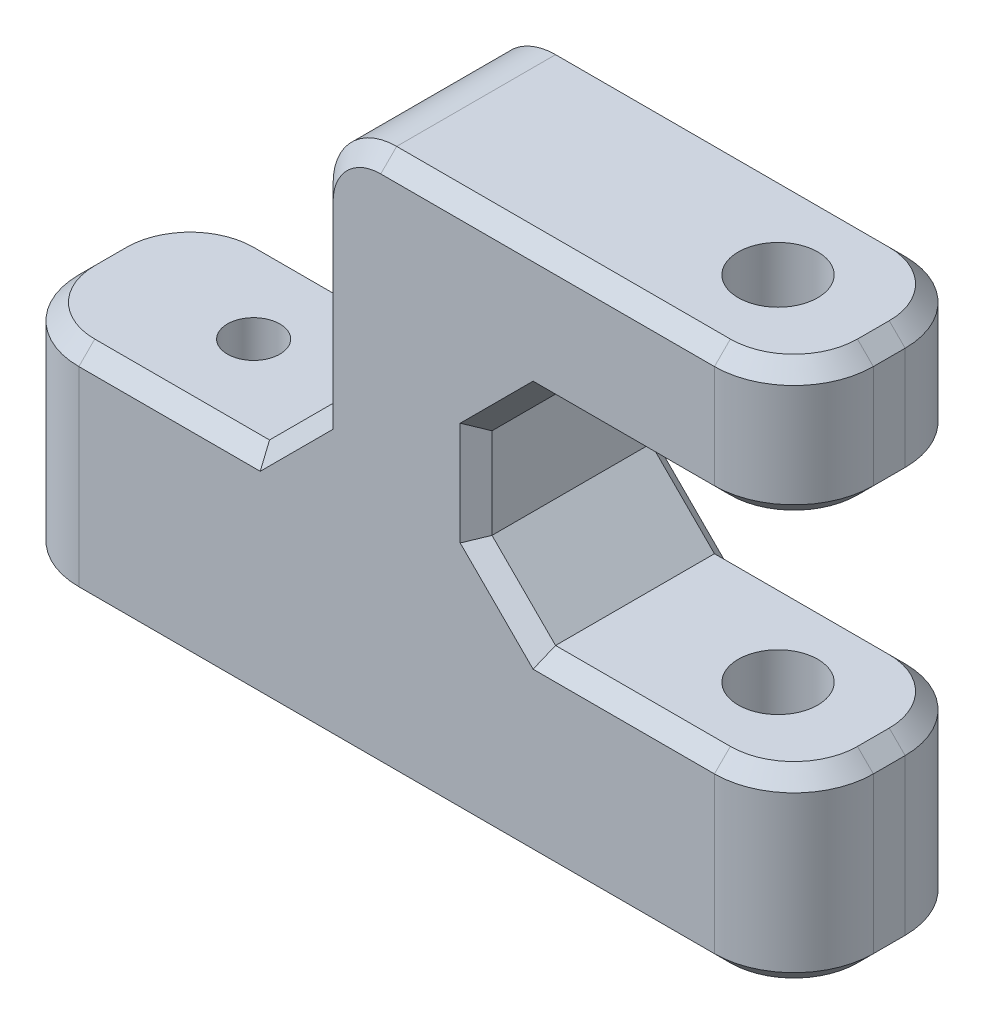
from build123d import *

# Parameters (mm, degrees)
BOSS_EXTRUDE1_DEPTH = 6
SKETCH2_R           = 1.65
CUT_EXTRUDE1_DEPTH  = 20
SKETCH3_R           = 2.5
CUT_EXTRUDE2_DEPTH  = 30
CHAMFER1_SIZE       = 4
FILLET1_R           = 4
FILLET2_R           = 5
CHAMFER2_SIZE       = 1


with BuildPart() as part:
    # Sketch1 → Boss-Extrude1 (new body, symmetric)
    with BuildSketch(Plane.XY):
        Polygon((0, 14), (0, 34), (30, 34), (30, 25.5), (10, 25.5), (10, 11.8), (30, 11.8), (30, 0), (0, 0), (-20, 0), (-20, 14), align=None)
    extrude(amount=BOSS_EXTRUDE1_DEPTH, both=True)

    # Sketch2 → Cut-Extrude1 (cut)
    with BuildSketch(Plane(origin=(0, 14, 0), x_dir=(1, 0, 0), z_dir=(0, 1, 0))):
        with Locations((-10, 0)):
            Circle(SKETCH2_R)
    extrude(amount=-CUT_EXTRUDE1_DEPTH, mode=Mode.SUBTRACT)

    # Sketch3 → Cut-Extrude2 (cut, symmetric)
    with BuildSketch(Plane(origin=(0, 11.8, 0), x_dir=(1, 0, 0), z_dir=(0, 1, 0))):
        with Locations((23, 0)):
            Circle(SKETCH3_R)
    extrude(amount=CUT_EXTRUDE2_DEPTH, both=True, mode=Mode.SUBTRACT)

    # Chamfer1
    chamfer1_edges = [part.edges().sort_by_distance(p)[0] for p in [
        (0, 14, 0),
        (10, 25.5, 0),
        (10, 11.8, 0),
    ]]
    chamfer(chamfer1_edges, length=CHAMFER1_SIZE)

    # Fillet1
    fillet1_edges = [part.edges().sort_by_distance(p)[0] for p in [
        (0, 34, 0),
    ]]
    fillet(fillet1_edges, radius=FILLET1_R)

    # Fillet2
    fillet2_edges = [part.edges().sort_by_distance(p)[0] for p in [
        (-20, 7, -6),
        (30, 29.75, -6),
        (30, 5.9, 6),
        (30, 5.9, -6),
        (30, 29.75, 6),
        (-20, 7, 6),
    ]]
    fillet(fillet2_edges, radius=FILLET2_R)

    # Chamfer2
    chamfer2_edges = [part.edges().sort_by_distance(p)[0] for p in [
        (-9.5, 14, -6),
        (-9.5, 14, 6),
        (10, 18.65, -6),
        (10, 18.65, 6),
        (19.5, 25.5, -6),
        (19.5, 25.5, 6),
        (-2, 16, -6),
        (-2, 16, 6),
        (12, 13.8, -6),
        (12, 13.8, 6),
        (12, 23.5, -6),
        (12, 23.5, 6),
        (0, 24, -6),
        (0, 24, 6),
        (1.171572875, 32.828427125, -6),
        (1.171572875, 32.828427125, 6),
        (30, 34, 0),
        (30, 25.5, 0),
        (14.5, 34, -6),
        (14.5, 34, 6),
        (28.535533906, 34, 4.535533906),
        (28.535533906, 34, -4.535533906),
        (19.5, 11.8, -6),
        (5, 0, -6),
        (28.535533906, 25.5, 4.535533906),
        (28.535533906, 25.5, -4.535533906),
        (5, 0, 6),
        (19.5, 11.8, 6),
        (30, 11.8, 0),
        (30, 0, 0),
        (28.535533906, 11.8, 4.535533906),
        (28.535533906, 11.8, -4.535533906),
        (-20, 0, 0),
        (-18.535533906, 0, 4.535533906),
        (-18.535533906, 0, -4.535533906),
        (28.535533906, 0, 4.535533906),
        (28.535533906, 0, -4.535533906),
        (-20, 14, 0),
        (-18.535533906, 14, 4.535533906),
        (-18.535533906, 14, -4.535533906),
    ]]
    chamfer(chamfer2_edges, length=CHAMFER2_SIZE)


solid = part.part
